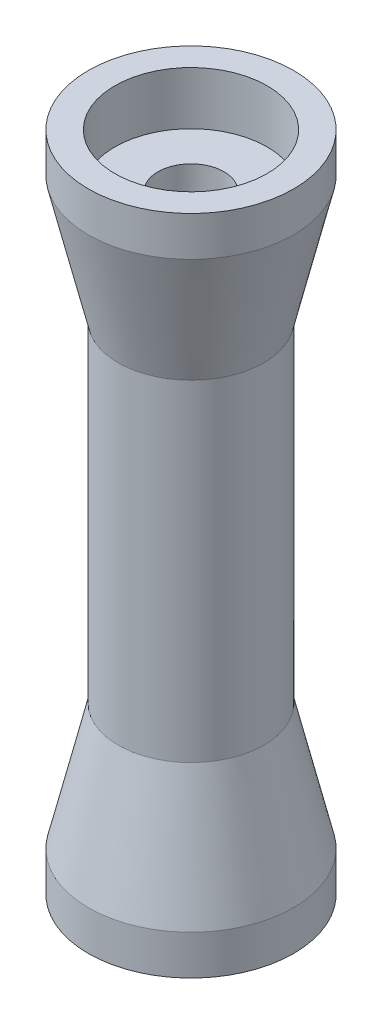
from build123d import *


with BuildPart() as part:
    # Esboço1 → Revolução1 (revolve)
    with BuildSketch(Plane.XY):
        Polygon((11, 25), (15.5, 6), (15.5, 0), (11.5, 0), (11.5, 8), (5, 8), (5, 92), (11.5, 92), (11.5, 100), (15.5, 100), (15.5, 94), (11, 75), align=None)
    revolve(axis=Axis((0, 0, 0), (0, 1, 0)))


solid = part.part
